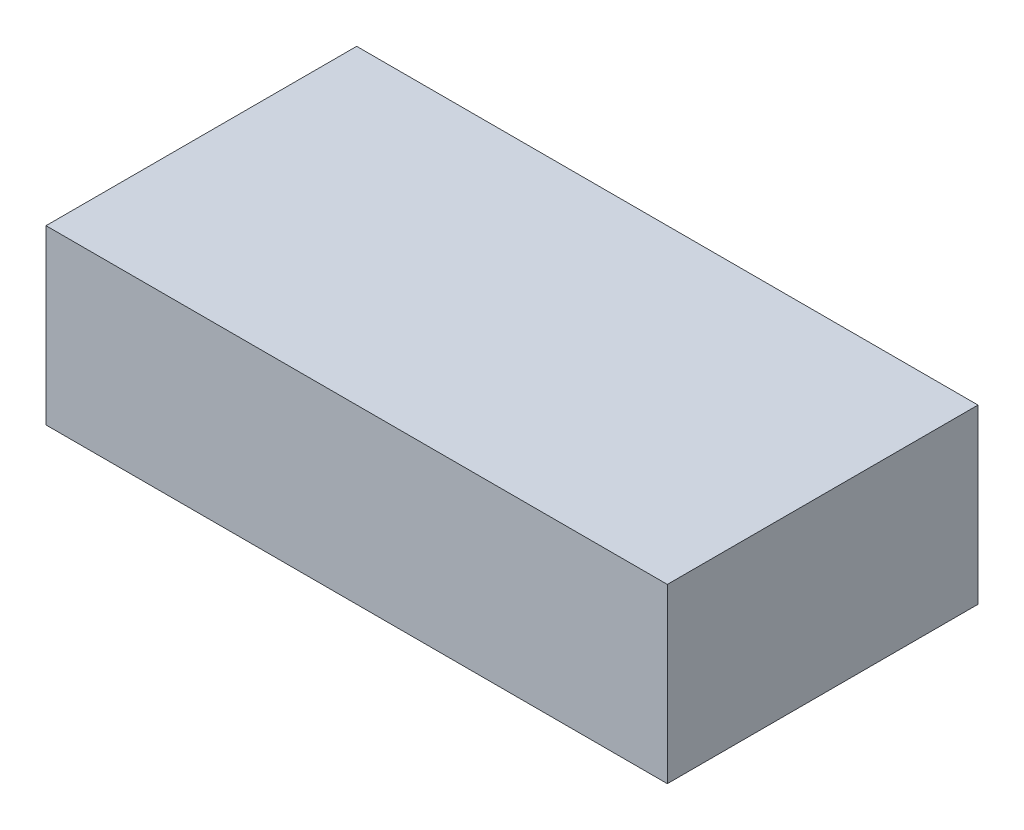
from build123d import *

# Parameters (mm, degrees)
SKETCH1_W           = 228.6
SKETCH1_H           = 114.3
BOSS_EXTRUDE1_DEPTH = 63.5
SKETCH2_R           = 1.5875
CUT_EXTRUDE1_DEPTH  = 6.35


with BuildPart() as part:
    # Sketch1 → Boss-Extrude1 (new body)
    with BuildSketch(Plane(origin=(0, 0, 0), x_dir=(1, 0, 0), z_dir=(0, 1, 0))):
        Rectangle(SKETCH1_W, SKETCH1_H)
    extrude(amount=BOSS_EXTRUDE1_DEPTH)

    # Sketch2 → Cut-Extrude1 (cut)
    with BuildSketch(Plane.ZY.offset(114.3)):
        with Locations((-38.1, 57.15)):
            Circle(SKETCH2_R)
        with Locations((38.1, 57.15)):
            Circle(SKETCH2_R)
    extrude(amount=-CUT_EXTRUDE1_DEPTH, mode=Mode.SUBTRACT)


solid = part.part
